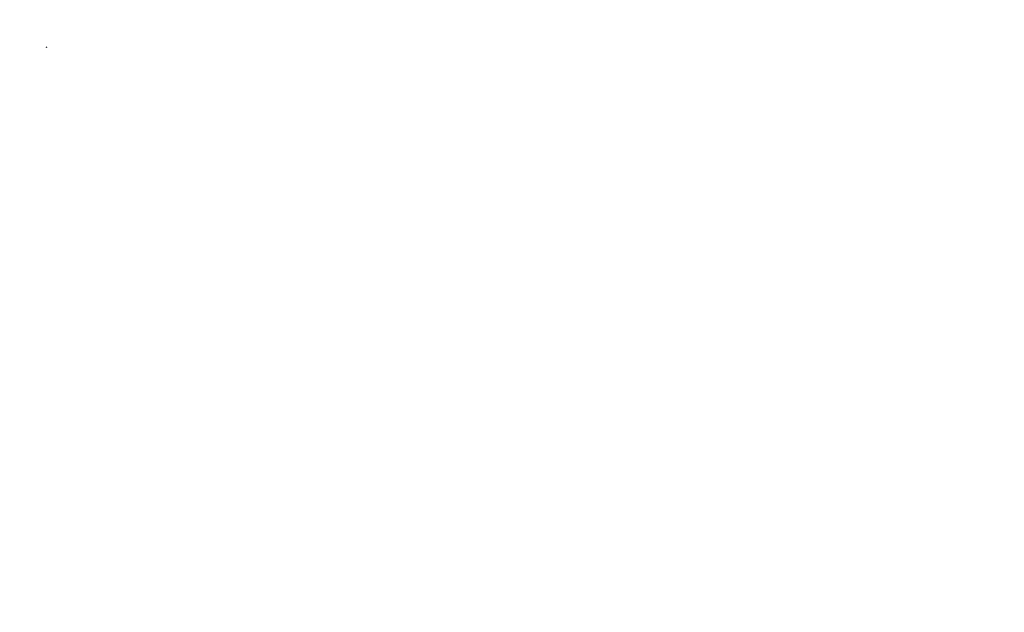
from build123d import *


with BuildPart() as part:
    # Sketch1 → Revolve-Sun (revolve)
    with BuildSketch(Plane(origin=(0, 0, 0), x_dir=(1, 0, 0), z_dir=(0, 1, 0))):
        with BuildLine():
            Line((0, 10.98423), (0, -10.98423))
            ThreePointArc((0, -10.98423), (10.98423, 0), (0, 10.98423))
        make_face()
    revolve(axis=Axis((0, 0, -10.98423), (0, 0, 1)))


with BuildPart() as body_2:
    # Sketch10 → Revolve-Mercury (revolve)
    with BuildSketch(Plane(origin=(0, 0, 0), x_dir=(1, 0, 0), z_dir=(0, 1, 0))):
        with BuildLine():
            Line((456.984354, 0.0393573), (456.984354, -0.0393573))
            ThreePointArc((456.984354, -0.0393573), (457.0237113, 0), (456.984354, 0.0393573))
        make_face()
    revolve(axis=Axis((456.984354, 0, -0.0393573), (0, 0, 1)))


with BuildPart() as body_3:
    # Sketch9 → Revolve-Venus (revolve)
    with BuildSketch(Plane(origin=(0, 0, 0), x_dir=(1, 0, 0), z_dir=(0, 1, 0))):
        with BuildLine():
            Line((853.923489, 0.0955167), (853.923489, -0.0955167))
            ThreePointArc((853.923489, -0.0955167), (854.0190057, 0), (853.923489, 0.0955167))
        make_face()
    revolve(axis=Axis((853.923489, 0, -0.0955167), (0, 0, 1)))


with BuildPart() as body_4:
    # Sketch7 → Revolve-Earth (revolve)
    with BuildSketch(Plane(origin=(0, 0, 0), x_dir=(1, 0, 0), z_dir=(0, 1, 0))):
        with BuildLine():
            Line((1180.541835, 0.1005586), (1180.541835, -0.1005586))
            ThreePointArc((1180.541835, -0.1005586), (1180.6423936, 0), (1180.541835, 0.1005586))
        make_face()
    revolve(axis=Axis((1180.541835, 0, -0.1005586), (0, 0, 1)))


with BuildPart() as body_5:
    # Sketch8 → Revolve-Moon (revolve)
    with BuildSketch(Plane(origin=(0, 0, 0), x_dir=(1, 0, 0), z_dir=(0, 1, 0))):
        with BuildLine():
            Line((1183.5752935, 0.0274193), (1183.5752935, -0.0274193))
            ThreePointArc((1183.5752935, -0.0274193), (1183.6027128, 0), (1183.5752935, 0.0274193))
        make_face()
    revolve(axis=Axis((1183.5752935, 0, -0.0274193), (0, 0, 1)))


with BuildPart() as body_6:
    # Sketch6 → Revolve-Mars (revolve)
    with BuildSketch(Plane(origin=(0, 0, 0), x_dir=(1, 0, 0), z_dir=(0, 1, 0))):
        with BuildLine():
            Line((1798.76196, 0.0534416), (1798.76196, -0.0534416))
            ThreePointArc((1798.76196, -0.0534416), (1798.8154016, 0), (1798.76196, 0.0534416))
        make_face()
    revolve(axis=Axis((1798.76196, 0, -0.0534416), (0, 0, 1)))


with BuildPart() as body_7:
    # Sketch5 → Revolve-Jupiter (revolve)
    with BuildSketch(Plane(origin=(0, 0, 0), x_dir=(1, 0, 0), z_dir=(0, 1, 0))):
        with BuildLine():
            Line((6143.83836, 1.0917428), (6143.83836, -1.0917428))
            ThreePointArc((6143.83836, -1.0917428), (6144.9301028, 0), (6143.83836, 1.0917428))
        make_face()
    revolve(axis=Axis((6143.83836, 0, -1.0917428), (0, 0, 1)))


with BuildPart() as body_8:
    # Sketch4 → Revolve-Saturn (revolve)
    with BuildSketch(Plane(origin=(0, 0, 0), x_dir=(1, 0, 0), z_dir=(0, 1, 0))):
        with BuildLine():
            Line((11311.94207, 0.9046083), (11311.94207, -0.9046083))
            ThreePointArc((11311.94207, -0.9046083), (11312.8466783, 0), (11311.94207, 0.9046083))
        make_face()
    revolve(axis=Axis((11311.94207, 0, -0.9046083), (0, 0, 1)))


with BuildPart() as body_9:
    # Sketch3 → Revolve-Uranus (revolve)
    with BuildSketch(Plane(origin=(0, 0, 0), x_dir=(1, 0, 0), z_dir=(0, 1, 0))):
        with BuildLine():
            Line((22701.0722, 0.3987673), (22701.0722, -0.3987673))
            ThreePointArc((22701.0722, -0.3987673), (22701.4709673, 0), (22701.0722, 0.3987673))
        make_face()
    revolve(axis=Axis((22701.0722, 0, -0.3987673), (0, 0, 1)))


with BuildPart() as body_10:
    # Sketch2 → Revolve-Neptune (revolve)
    with BuildSketch(Plane(origin=(0, 0, 0), x_dir=(1, 0, 0), z_dir=(0, 1, 0))):
        with BuildLine():
            Line((35538.41, 0.3875024), (35538.41, -0.3875024))
            ThreePointArc((35538.41, -0.3875024), (35538.7975024, 0), (35538.41, 0.3875024))
        make_face()
    revolve(axis=Axis((35538.41, 0, -0.3875024), (0, 0, 1)))


solid = Compound([part.part, body_2.part, body_3.part, body_4.part, body_5.part, body_6.part, body_7.part, body_8.part, body_9.part, body_10.part])
